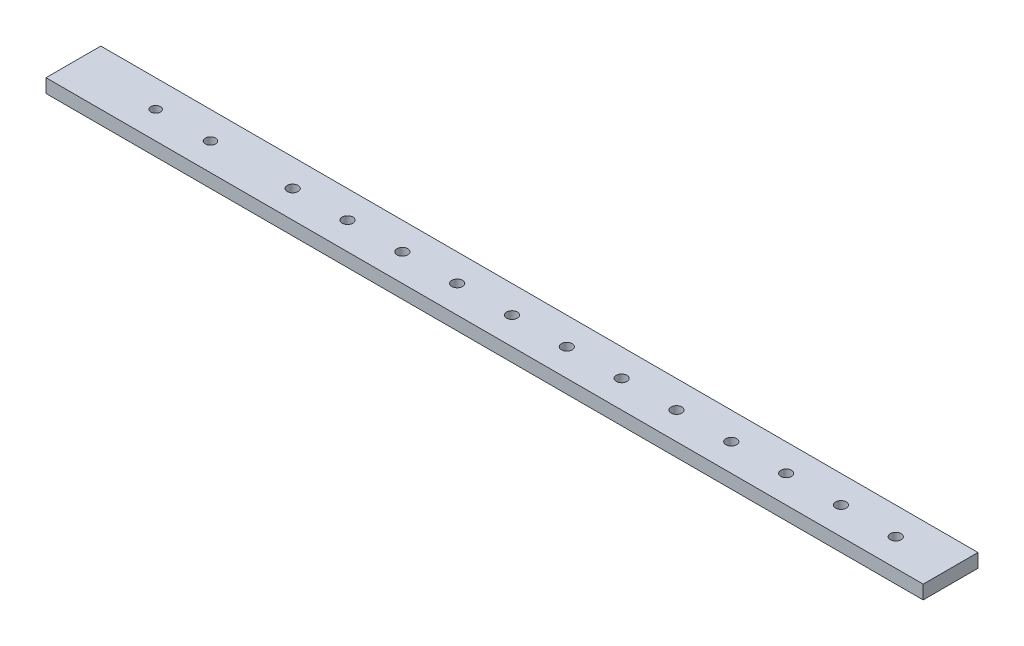
from build123d import *

# Parameters (mm, degrees)
SKETCH1_W               = 406.4
SKETCH1_H               = 25.4
BOSS_EXTRUDE1_DEPTH     = 6.35
SKETCH2_R               = 2.4892
CUT_EXTRUDE1_DEPTH      = 1
CUT_EXTRUDE1_DEPTH_BACK = 7.35
SKETCH3_R               = 2.378070279
SKETCH3_R_2             = 2.20737703
CUT_EXTRUDE2_DEPTH      = 7.35


with BuildPart() as part:
    # Sketch1 → Boss-Extrude1 (new body)
    with BuildSketch(Plane(origin=(0, 0, 0), x_dir=(1, 0, 0), z_dir=(0, 1, 0))):
        with Locations((203.2, 12.7)):
            Rectangle(SKETCH1_W, SKETCH1_H)
    extrude(amount=BOSS_EXTRUDE1_DEPTH)

    # Sketch2 → Cut-Extrude1 (cut, two sides)
    with BuildSketch(Plane(origin=(0, 6.35, 0), x_dir=(1, 0, 0), z_dir=(0, 1, 0))) as cut_extrude1_sk:
        with Locations((381, 12.7)):
            Circle(SKETCH2_R)
        with Locations((355.6, 12.7)):
            Circle(SKETCH2_R)
        with Locations((330.2, 12.7)):
            Circle(SKETCH2_R)
        with Locations((304.8, 12.7)):
            Circle(SKETCH2_R)
        with Locations((279.4, 12.7)):
            Circle(SKETCH2_R)
        with Locations((254, 12.7)):
            Circle(SKETCH2_R)
        with Locations((228.6, 12.7)):
            Circle(SKETCH2_R)
        with Locations((203.2, 12.7)):
            Circle(SKETCH2_R)
        with Locations((177.8, 12.7)):
            Circle(SKETCH2_R)
        with Locations((152.4, 12.7)):
            Circle(SKETCH2_R)
        with Locations((127, 12.7)):
            Circle(SKETCH2_R)
        with Locations((101.6, 12.7)):
            Circle(SKETCH2_R)
    extrude(amount=CUT_EXTRUDE1_DEPTH, mode=Mode.SUBTRACT)
    extrude(cut_extrude1_sk.sketch, amount=-CUT_EXTRUDE1_DEPTH_BACK, mode=Mode.SUBTRACT)

    # Sketch3 → Cut-Extrude2 (cut, through all)
    with BuildSketch(Plane.XZ):
        with Locations((63.5, -12.7)):
            Circle(SKETCH3_R)
        with Locations((38.1, -12.7)):
            Circle(SKETCH3_R_2)
    extrude(amount=-CUT_EXTRUDE2_DEPTH, mode=Mode.SUBTRACT)


solid = part.part
